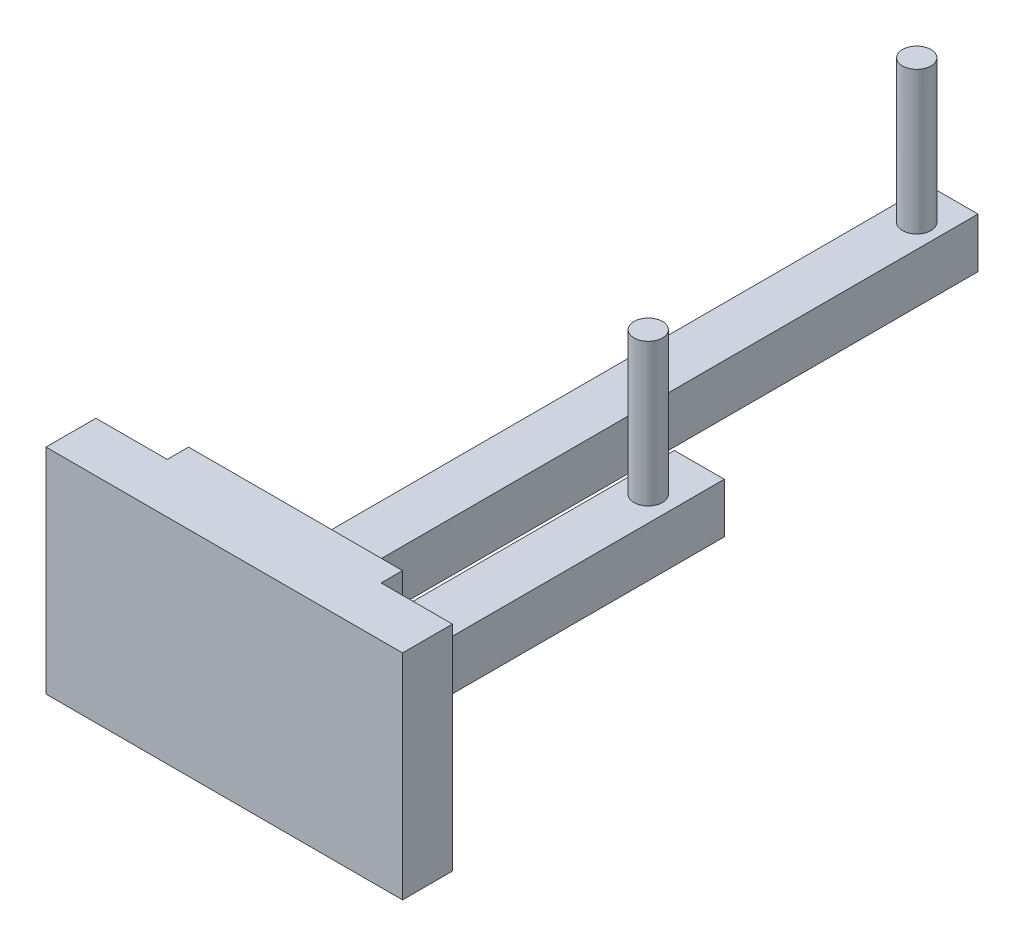
from build123d import *

# Parameters (mm, degrees)
SKETCH1_W            = 10
SKETCH1_H            = 30
SKETCH1_W_2          = 30
BOSS_EXTRUDE4_DEPTH  = 7
SKETCH3_W            = 30
SKETCH3_H            = 30
BOSS_EXTRUDE5_DEPTH  = 3
SKETCH4_W            = 7
SKETCH4_H            = 7
BOSS_EXTRUDE8_DEPTH  = 50
SKETCH6_R            = 2
BOSS_EXTRUDE9_DEPTH  = 20
SKETCH7_W            = 7
SKETCH7_H            = 7
BOSS_EXTRUDE13_DEPTH = 100
SKETCH10_R           = 2
BOSS_EXTRUDE14_DEPTH = 20


with BuildPart() as part:
    # Sketch1 → Boss-Extrude4 (new body)
    with BuildSketch(Plane.XY):
        with Locations((-20, 0)):
            Rectangle(SKETCH1_W, SKETCH1_H)
        Rectangle(SKETCH1_W_2, SKETCH1_H)
        with Locations((20, 0)):
            Rectangle(SKETCH1_W, SKETCH1_H)
    extrude(amount=BOSS_EXTRUDE4_DEPTH)

    # Sketch3 → Boss-Extrude5 (add)
    with BuildSketch(Plane(origin=(0, 0, 0), x_dir=(-1, 0, 0), z_dir=(0, 0, -1))):
        Rectangle(SKETCH3_W, SKETCH3_H)
    extrude(amount=BOSS_EXTRUDE5_DEPTH)

    # Sketch4 → Boss-Extrude8 (add)
    with BuildSketch(Plane(origin=(0, 0, -3), x_dir=(-1, 0, 0), z_dir=(0, 0, -1))):
        with Locations((-6.620919375, -4.848854148)):
            Rectangle(SKETCH4_W, SKETCH4_H)
    extrude(amount=BOSS_EXTRUDE8_DEPTH)

    # Sketch6 → Boss-Extrude9 (add)
    with BuildSketch(Plane(origin=(0, -1.348854148, 0), x_dir=(1, 0, 0), z_dir=(0, 1, 0))):
        with Locations((6.620919375, 45.83776359)):
            Circle(SKETCH6_R)
    extrude(amount=BOSS_EXTRUDE9_DEPTH)

    # Sketch7 → Boss-Extrude13 (add)
    with BuildSketch(Plane(origin=(0, 0, -3), x_dir=(-1, 0, 0), z_dir=(0, 0, -1))):
        with Locations((7.796290003, -4.848854148)):
            Rectangle(SKETCH7_W, SKETCH7_H)
    extrude(amount=BOSS_EXTRUDE13_DEPTH)

    # Sketch10 → Boss-Extrude14 (add)
    with BuildSketch(Plane(origin=(0, -1.348854148, 0), x_dir=(1, 0, 0), z_dir=(0, 1, 0))):
        with Locations((-7.583363056, 97.696042798)):
            Circle(SKETCH10_R)
    extrude(amount=BOSS_EXTRUDE14_DEPTH)


solid = part.part
